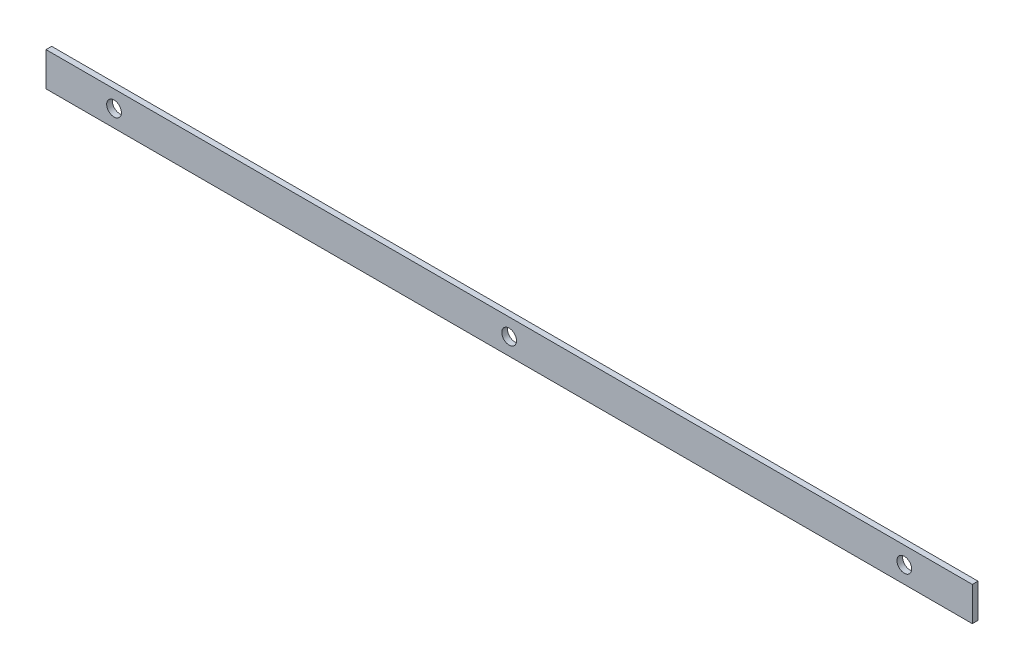
from build123d import *

# Parameters (mm, degrees)
PLAT_W                          = 30
PLAT_H                          = 5
EL_MENT_M_CANO_SOUD_1_DEPTH     = 817
DIAM_TRE_DU_PER_AGE_13_0_13_1_D = 13
R_P_TITION_LIN_AIRE2_COUNT      = 3
R_P_TITION_LIN_AIRE2_PITCH      = 348.5


with BuildPart() as part:
    # plat → Elément mécano-soudé1 (new body)
    with BuildSketch(Plane.YZ.offset(-408.5)):
        Rectangle(PLAT_W, PLAT_H)
    extrude(amount=EL_MENT_M_CANO_SOUD_1_DEPTH)

    # Diamètre du perçage Ø13.0 (13)1 (through all)
    with Locations(Plane(origin=(0, 0, -2.5), x_dir=(-1, 0, 0), z_dir=(0, 0, -1))):
        with Locations((348.5, 0)):
            diam_tre_du_per_age_13_0_13_1 = Hole(DIAM_TRE_DU_PER_AGE_13_0_13_1_D / 2)

    # Répétition linéaire2: Diamètre du perçage Ø13.0 (13)1 ×3
    with Locations(*[(i * R_P_TITION_LIN_AIRE2_PITCH, 0, 0) for i in range(1, R_P_TITION_LIN_AIRE2_COUNT)]):
        add(diam_tre_du_per_age_13_0_13_1, mode=Mode.SUBTRACT)


solid = part.part
